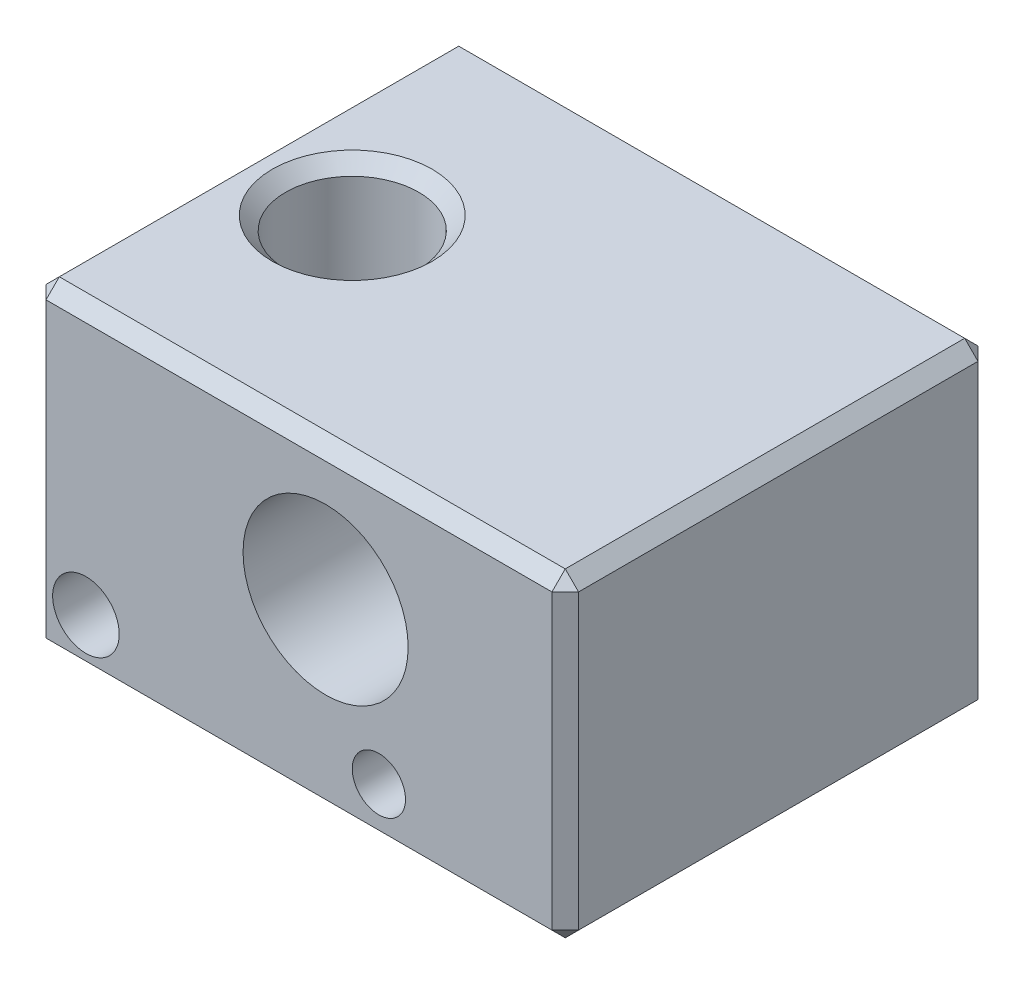
from build123d import *

# Parameters (mm, degrees)
SKETCH1_W                       = 20
SKETCH1_H                       = 16
BOSS_EXTRUDE1_DEPTH             = 12
SKETCH2_R                       = 3.1
SKETCH2_R_2                     = 1
CUT_EXTRUDE1_DEPTH              = 17
F_2_5_2_5_DIAMETER_HOLE1_D      = 2.5
F_2_5_2_5_DIAMETER_HOLE1_DEPTH  = 4.5
TAP_DRILL_FOR_M6X1_0_TAP1_D     = 5
TAP_DRILL_FOR_M3X0_5_TAP1_D     = 2.5
TAP_DRILL_FOR_M3X0_5_TAP1_DEPTH = 6.999
TAP_DRILL_FOR_M3X0_5_TAP1_TIP   = 0.751075774
CHAMFER1_SIZE                   = 0.5


with BuildPart() as part:
    # Sketch1 → Boss-Extrude1 (new body)
    with BuildSketch(Plane(origin=(0, 0, 0), x_dir=(1, 0, 0), z_dir=(0, 1, 0))):
        Rectangle(SKETCH1_W, SKETCH1_H)
    extrude(amount=BOSS_EXTRUDE1_DEPTH)

    # Sketch2 → Cut-Extrude1 (cut, through all)
    with BuildSketch(Plane.XY.offset(8)):
        with Locations((1, 7)):
            Circle(SKETCH2_R)
        with Locations((3, 2)):
            Circle(SKETCH2_R_2)
    extrude(amount=-CUT_EXTRUDE1_DEPTH, mode=Mode.SUBTRACT)

    # Ø2.5 (2.5) Diameter Hole1
    with Locations(Plane.XY.offset(8)):
        with Locations((-8, 2)):
            Hole(F_2_5_2_5_DIAMETER_HOLE1_D / 2, depth=F_2_5_2_5_DIAMETER_HOLE1_DEPTH)

    # Tap Drill for M6x1.0 Tap1 (through all)
    with Locations(Plane(origin=(0, 12, 0), x_dir=(1, 0, 0), z_dir=(0, 1, 0))):
        with Locations((-6, 0)):
            Hole(TAP_DRILL_FOR_M6X1_0_TAP1_D / 2)

    # Tap Drill for M3x0.5 Tap1
    with Locations(Plane(origin=(0, 0, 0), x_dir=(-1, 0, 0), z_dir=(0, -1, 0))):
        with Locations((0, 0)):
            Hole(TAP_DRILL_FOR_M3X0_5_TAP1_D / 2, depth=TAP_DRILL_FOR_M3X0_5_TAP1_DEPTH)
            with Locations((0, 0, -(TAP_DRILL_FOR_M3X0_5_TAP1_DEPTH + TAP_DRILL_FOR_M3X0_5_TAP1_TIP / 2))):  # 118° drill point
                Cone(0, TAP_DRILL_FOR_M3X0_5_TAP1_D / 2, TAP_DRILL_FOR_M3X0_5_TAP1_TIP, mode=Mode.SUBTRACT)

    # Chamfer1
    chamfer1_edges = [part.edges().sort_by_distance(p)[0] for p in [
        (0, 12, -8),
        (-10, 12, 0),
        (-3.5, 12, 0),
        (-3.5, 0, 0),
        (-1.25, 0, 0),
        (0, 12, 8),
        (-10, 0, 0),
        (0, 0, -8),
        (10, 0, 0),
        (0, 0, 8),
        (10, 12, 0),
        (-10, 6, 8),
        (-10, 6, -8),
        (10, 6, -8),
        (10, 6, 8),
    ]]
    chamfer(chamfer1_edges, length=CHAMFER1_SIZE)


solid = part.part
